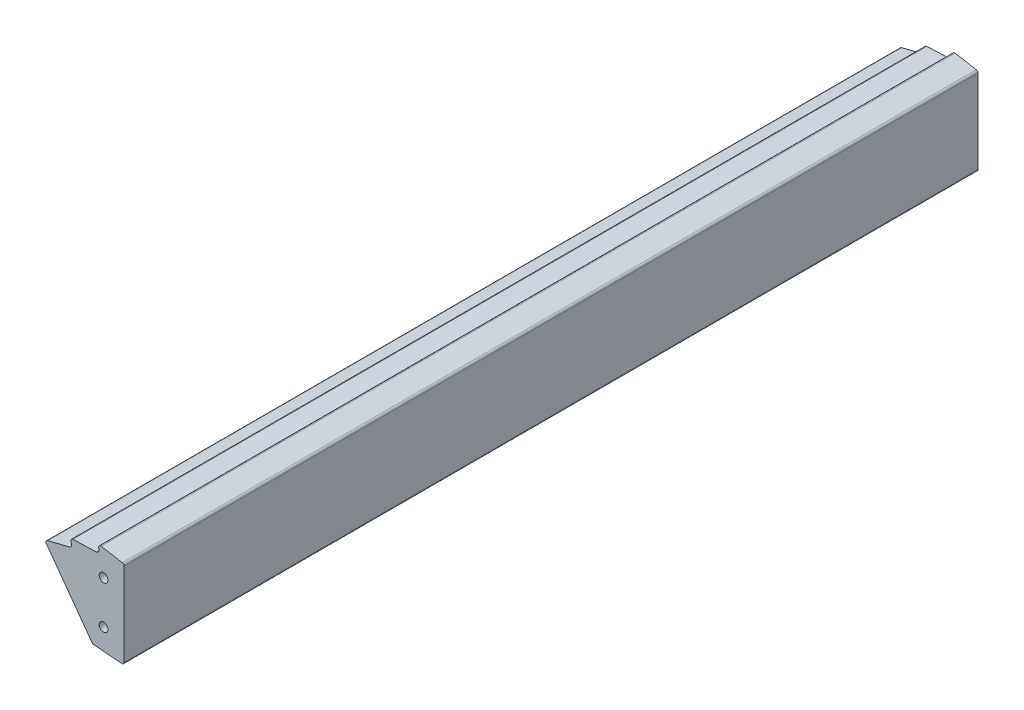
from build123d import *

# Parameters (mm, degrees)
EXTRUDE_THIN1_DEPTH                   = 137.50025
EXTRUDE_THIN1_DEPTH_BACK              = 213.5
BOSS_EXTRUDE1_DEPTH                   = 212.50025
BOSS_EXTRUDE1_DEPTH_BACK              = 288.5
SKETCH3_OUTSIDE_W                     = 604.182
SKETCH3_OUTSIDE_H                     = 156.652
SKETCH3_OUTSIDE_W_2                   = 500
SKETCH3_OUTSIDE_H_2                   = 100
CUT_EXTRUDE1_DEPTH                    = 47.972186303
F_1_4_20_TAPPED_HOLE1_D               = 5.1054
F_1_4_20_TAPPED_HOLE1_DEPTH           = 16.51
F_1_4_20_TAPPED_HOLE1_TIP             = 1.533816902
F_1_4_20_TAPPED_HOLE1_ON_FACE_2_D     = 5.1054
F_1_4_20_TAPPED_HOLE1_ON_FACE_2_DEPTH = 16.51
F_1_4_20_TAPPED_HOLE1_ON_FACE_2_TIP   = 1.533816902


with BuildPart() as part:
    # Sketch1 → Extrude-Thin1 (new body, two sides)
    with BuildSketch(Plane.XY) as extrude_thin1_sk:
        with BuildLine():
            Line((-1, 29.097280522), (-1, 77.801426037))
            ThreePointArc((-1, 77.801426037), (-1.350622843, 78.7652373), (-2.238576202, 79.27846957))
            Line((-2.238576202, 79.27846957), (-14.558703222, 81.459024393))
            ThreePointArc((-14.558703222, 81.459024393), (-15.894736772, 81.028505528), (-16.289731153, 79.68154169))
            Line((-16.289731153, 79.68154169), (-16.133756175, 78.918587006))
            ThreePointArc((-16.133756175, 78.918587006), (-16.425245764, 77.689683446), (-17.55197675, 77.119028185))
            Line((-17.55197675, 77.119028185), (-31.176844121, 76.652024665))
            ThreePointArc((-31.176844121, 76.652024665), (-32.394172227, 75.953136676), (-32.500485503, 74.55348328))
            Line((-32.500485503, 74.55348328), (-32.189291755, 73.839630008))
            ThreePointArc((-32.189291755, 73.839630008), (-32.21890818, 72.576976846), (-33.20237149, 71.784531227))
            Line((-33.20237149, 71.784531227), (-46.048094305, 68.590520727))
            ThreePointArc((-46.048094305, 68.590520727), (-47.095522717, 67.648327863), (-46.899674591, 66.2531658))
            Line((-46.899674591, 66.2531658), (-20.221033316, 29.533166286))
            ThreePointArc((-20.221033316, 29.533166286), (-19.7411642, 29.106506164), (-19.126852316, 28.919599404))
            Line((-19.126852316, 28.919599404), (-2.619344492, 27.602035762))
            ThreePointArc((-2.619344492, 27.602035762), (-1.482408908, 27.995233168), (-1, 29.097280522))
        make_face()
        with BuildLine():
            Line((-1.27, 29.097280522), (-1.27, 77.801426037))
            ThreePointArc((-1.27, 77.801426037), (-1.557510731, 78.591751273), (-2.285632486, 79.012601734))
            Line((-2.285632486, 79.012601734), (-14.605759506, 81.193156557))
            ThreePointArc((-14.605759506, 81.193156557), (-15.701307017, 80.840131088), (-16.025202409, 79.735620741))
            Line((-16.025202409, 79.735620741), (-15.869227431, 78.972666057))
            ThreePointArc((-15.869227431, 78.972666057), (-16.213185147, 77.522559856), (-17.542727709, 76.849186648))
            Line((-17.542727709, 76.849186648), (-31.16759508, 76.382183127))
            ThreePointArc((-31.16759508, 76.382183127), (-32.165804128, 75.809094976), (-32.252981014, 74.661379192))
            Line((-32.252981014, 74.661379192), (-31.941787266, 73.94752592))
            ThreePointArc((-31.941787266, 73.94752592), (-31.976734648, 72.457595189), (-33.137221353, 71.522509358))
            Line((-33.137221353, 71.522509358), (-45.982944168, 68.328498858))
            ThreePointArc((-45.982944168, 68.328498858), (-46.841835466, 67.55590071), (-46.681240003, 66.411867819))
            Line((-46.681240003, 66.411867819), (-20.002598727, 29.691868304))
            ThreePointArc((-20.002598727, 29.691868304), (-19.609106053, 29.342007004), (-19.105370308, 29.188743461))
            Line((-19.105370308, 29.188743461), (-2.597862483, 27.871179818))
            ThreePointArc((-2.597862483, 27.871179818), (-1.665575304, 28.193601692), (-1.27, 29.097280522))
        make_face(mode=Mode.SUBTRACT)
    extrude(amount=EXTRUDE_THIN1_DEPTH)
    extrude(extrude_thin1_sk.sketch, amount=-EXTRUDE_THIN1_DEPTH_BACK)


with BuildPart() as body_2:
    # Sketch2 → Boss-Extrude1 (new body, two sides)
    with BuildSketch(Plane.XY) as boss_extrude1_sk:
        with BuildLine():
            Line((-46.68124, 66.411867814), (-20.002598727, 29.691868304))
            ThreePointArc((-20.002598727, 29.691868304), (-19.609106053, 29.342007004), (-19.105370308, 29.188743461))
            Line((-19.105370308, 29.188743461), (-2.597862483, 27.871179818))
            ThreePointArc((-2.597862483, 27.871179818), (-1.665575304, 28.193601692), (-1.27, 29.097280522))
            Line((-1.27, 29.097280522), (-1.27, 77.801426032))
            Line((-1.27, 77.801426032), (-1.27, 77.950492716))
            ThreePointArc((-1.27, 77.950492716), (-1.551343626, 78.723865476), (-2.263847169, 79.135688695))
            Line((-2.263847169, 79.135688695), (-14.583974189, 81.316243518))
            ThreePointArc((-14.583974189, 81.316243518), (-15.79085783, 80.927341477), (-16.14766942, 79.710584143))
            Line((-16.14766942, 79.710584143), (-15.991694442, 78.947629459))
            ThreePointArc((-15.991694442, 78.947629459), (-16.311361359, 77.599931889), (-17.547009673, 76.974113285))
            Line((-17.547009673, 76.974113285), (-31.171877043, 76.507109765))
            ThreePointArc((-31.171877043, 76.507109765), (-32.271530099, 75.875780948), (-32.367566426, 74.611427381))
            Line((-32.367566426, 74.611427381), (-32.056372677, 73.897574109))
            ThreePointArc((-32.056372677, 73.897574109), (-32.088852024, 72.512864474), (-33.167383454, 71.643815779))
            Line((-33.167383454, 71.643815779), (-46.013106268, 68.449805279))
            ThreePointArc((-46.013106268, 68.449805279), (-46.895812164, 67.655785195), (-46.730763849, 66.480031545))
            Line((-46.730763849, 66.480031545), (-46.68124, 66.411867814))
        make_face()
    extrude(amount=BOSS_EXTRUDE1_DEPTH)
    extrude(boss_extrude1_sk.sketch, amount=-BOSS_EXTRUDE1_DEPTH_BACK)

    # Sketch3 outside → Cut-Extrude1 (cut, through all)
    with BuildSketch(Plane(origin=(0, 0, 0), x_dir=(0, 0, -1), z_dir=(1, 0, 0))):
        with Locations((38, 54.602)):
            Rectangle(SKETCH3_OUTSIDE_W, SKETCH3_OUTSIDE_H)
        with Locations((37.999875, 53.523886616)):
            Rectangle(SKETCH3_OUTSIDE_W_2, SKETCH3_OUTSIDE_H_2, mode=Mode.SUBTRACT)
    extrude(amount=-CUT_EXTRUDE1_DEPTH, mode=Mode.SUBTRACT)

    # 1/4-20 Tapped Hole1
    with Locations(Plane(origin=(-13.27, 66.023886616, 212.000125), x_dir=(1, 0, 0), z_dir=(0, 0, 1))):
        with Locations((0, 0), (0, -25)):
            Hole(F_1_4_20_TAPPED_HOLE1_D / 2, depth=F_1_4_20_TAPPED_HOLE1_DEPTH)
            with Locations((0, 0, -(F_1_4_20_TAPPED_HOLE1_DEPTH + F_1_4_20_TAPPED_HOLE1_TIP / 2))):  # 118° drill point
                Cone(0, F_1_4_20_TAPPED_HOLE1_D / 2, F_1_4_20_TAPPED_HOLE1_TIP, mode=Mode.SUBTRACT)

    # 1/4-20 Tapped Hole1 on face 2
    with Locations(Plane(origin=(-13.27, 66.023886616, -287.999875), x_dir=(-1, 0, 0), z_dir=(0, 0, -1))):
        with Locations((0, 0), (0, -25)):
            Hole(F_1_4_20_TAPPED_HOLE1_ON_FACE_2_D / 2, depth=F_1_4_20_TAPPED_HOLE1_ON_FACE_2_DEPTH)
            with Locations((0, 0, -(F_1_4_20_TAPPED_HOLE1_ON_FACE_2_DEPTH + F_1_4_20_TAPPED_HOLE1_ON_FACE_2_TIP / 2))):  # 118° drill point
                Cone(0, F_1_4_20_TAPPED_HOLE1_ON_FACE_2_D / 2, F_1_4_20_TAPPED_HOLE1_ON_FACE_2_TIP, mode=Mode.SUBTRACT)


solid = body_2.part
